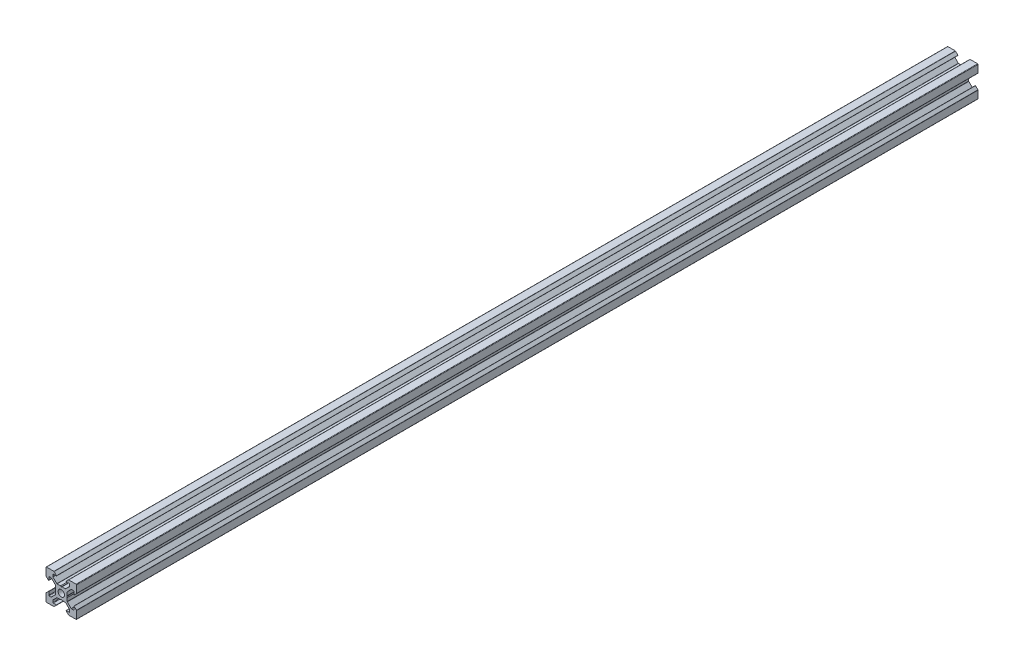
from build123d import *

# Parameters (mm, degrees)
BOSS_EXTRU_1_DEPTH = 590


with BuildPart() as part:
    # Esquisse1 → Boss.-Extru.1 (new body)
    with BuildSketch(Plane.XY):
        with BuildLine():
            Line((18.774857412, -2.895228684), (18.774857412, -4.894568513))
            ThreePointArc((18.774857412, -4.894568513), (18.686989447, -5.106700547), (18.474857412, -5.194568513))
            Line((18.474857412, -5.194568513), (17.259121481, -5.194568513))
            ThreePointArc((17.259121481, -5.194568513), (17.144316451, -5.171732372), (17.046989447, -5.106700547))
            Line((17.046989447, -5.106700547), (14.56338555, -2.62309665))
            ThreePointArc((14.56338555, -2.62309665), (14.498353724, -2.525769645), (14.475517584, -2.410964616))
            Line((14.475517584, -2.410964616), (14.475517584, -0.214843927))
            Line((14.475517584, -0.214843927), (14.175517584, 0.304771316))
            Line((14.175517584, 0.304771316), (14.475517584, 0.824386558))
            Line((14.475517584, 0.824386558), (14.475517584, 3.020507247))
            ThreePointArc((14.475517584, 3.020507247), (14.498353724, 3.135312277), (14.56338555, 3.232639281))
            Line((14.56338555, 3.232639281), (17.046989447, 5.716243178))
            ThreePointArc((17.046989447, 5.716243178), (17.144316451, 5.781275004), (17.259121481, 5.804111144))
            Line((17.259121481, 5.804111144), (18.474857412, 5.804111144))
            ThreePointArc((18.474857412, 5.804111144), (18.686989447, 5.716243178), (18.774857412, 5.504111144))
            Line((18.774857412, 5.504111144), (18.774857412, 3.504771316))
            ThreePointArc((18.774857412, 3.504771316), (18.836589069, 3.412383362), (18.94556809, 3.434060638))
            Line((18.94556809, 3.434060638), (20.486989447, 4.975481994))
            ThreePointArc((20.486989447, 4.975481994), (20.552021272, 5.072808998), (20.574857412, 5.187614028))
            Line((20.574857412, 5.187614028), (20.574857412, 10.004771316))
            ThreePointArc((20.574857412, 10.004771316), (20.486989447, 10.21690335), (20.274857412, 10.304771316))
            Line((20.274857412, 10.304771316), (15.457700125, 10.304771316))
            ThreePointArc((15.457700125, 10.304771316), (15.342895095, 10.281935175), (15.24556809, 10.21690335))
            Line((15.24556809, 10.21690335), (13.704146734, 8.675481994))
            ThreePointArc((13.704146734, 8.675481994), (13.682469459, 8.566502972), (13.774857412, 8.504771316))
            Line((13.774857412, 8.504771316), (15.77419724, 8.504771316))
            ThreePointArc((15.77419724, 8.504771316), (15.986329275, 8.41690335), (16.07419724, 8.204771316))
            Line((16.07419724, 8.204771316), (16.07419724, 6.989035384))
            ThreePointArc((16.07419724, 6.989035384), (16.0513611, 6.874230355), (15.986329275, 6.77690335))
            Line((15.986329275, 6.77690335), (13.502725378, 4.293299453))
            ThreePointArc((13.502725378, 4.293299453), (13.405398373, 4.228267628), (13.290593344, 4.205431487))
            Line((13.290593344, 4.205431487), (11.094472654, 4.205431487))
            Line((11.094472654, 4.205431487), (10.574857412, 3.905431487))
            Line((10.574857412, 3.905431487), (10.05524217, 4.205431487))
            Line((10.05524217, 4.205431487), (7.859121481, 4.205431487))
            ThreePointArc((7.859121481, 4.205431487), (7.744316451, 4.228267628), (7.646989447, 4.293299453))
            Line((7.646989447, 4.293299453), (5.16338555, 6.77690335))
            ThreePointArc((5.16338555, 6.77690335), (5.098353724, 6.874230355), (5.075517584, 6.989035384))
            Line((5.075517584, 6.989035384), (5.075517584, 8.204771316))
            ThreePointArc((5.075517584, 8.204771316), (5.16338555, 8.41690335), (5.375517584, 8.504771316))
            Line((5.375517584, 8.504771316), (7.374857412, 8.504771316))
            ThreePointArc((7.374857412, 8.504771316), (7.467245365, 8.566502972), (7.44556809, 8.675481994))
            Line((7.44556809, 8.675481994), (5.904146734, 10.21690335))
            ThreePointArc((5.904146734, 10.21690335), (5.806819729, 10.281935175), (5.6920147, 10.304771316))
            Line((5.6920147, 10.304771316), (0.874857412, 10.304771316))
            ThreePointArc((0.874857412, 10.304771316), (0.662725378, 10.21690335), (0.574857412, 10.004771316))
            Line((0.574857412, 10.004771316), (0.574857412, 5.187614028))
            ThreePointArc((0.574857412, 5.187614028), (0.597693552, 5.072808998), (0.662725378, 4.975481994))
            Line((0.662725378, 4.975481994), (2.204146734, 3.434060638))
            ThreePointArc((2.204146734, 3.434060638), (2.313125755, 3.412383362), (2.374857412, 3.504771316))
            Line((2.374857412, 3.504771316), (2.374857412, 5.504111144))
            ThreePointArc((2.374857412, 5.504111144), (2.462725378, 5.716243178), (2.674857412, 5.804111144))
            Line((2.674857412, 5.804111144), (3.890593344, 5.804111144))
            ThreePointArc((3.890593344, 5.804111144), (4.005398373, 5.781275004), (4.102725378, 5.716243178))
            Line((4.102725378, 5.716243178), (6.586329275, 3.232639281))
            ThreePointArc((6.586329275, 3.232639281), (6.6513611, 3.135312277), (6.67419724, 3.020507247))
            Line((6.67419724, 3.020507247), (6.67419724, 0.824386558))
            Line((6.67419724, 0.824386558), (6.97419724, 0.304771316))
            Line((6.97419724, 0.304771316), (6.67419724, -0.214843927))
            Line((6.67419724, -0.214843927), (6.67419724, -2.410964616))
            ThreePointArc((6.67419724, -2.410964616), (6.6513611, -2.525769645), (6.586329275, -2.62309665))
            Line((6.586329275, -2.62309665), (4.102725378, -5.106700547))
            ThreePointArc((4.102725378, -5.106700547), (4.005398373, -5.171732372), (3.890593344, -5.194568513))
            Line((3.890593344, -5.194568513), (2.674857412, -5.194568513))
            ThreePointArc((2.674857412, -5.194568513), (2.462725378, -5.106700547), (2.374857412, -4.894568513))
            Line((2.374857412, -4.894568513), (2.374857412, -2.895228684))
            ThreePointArc((2.374857412, -2.895228684), (2.313125755, -2.802840731), (2.204146734, -2.824518006))
            Line((2.204146734, -2.824518006), (0.662725378, -4.365939362))
            ThreePointArc((0.662725378, -4.365939362), (0.597693552, -4.463266367), (0.574857412, -4.578071397))
            Line((0.574857412, -4.578071397), (0.574857412, -9.395228684))
            ThreePointArc((0.574857412, -9.395228684), (0.662725378, -9.607360719), (0.874857412, -9.695228684))
            Line((0.874857412, -9.695228684), (5.6920147, -9.695228684))
            ThreePointArc((5.6920147, -9.695228684), (5.806819729, -9.672392544), (5.904146734, -9.607360719))
            Line((5.904146734, -9.607360719), (7.44556809, -8.065939362))
            ThreePointArc((7.44556809, -8.065939362), (7.467245365, -7.956960341), (7.374857412, -7.895228684))
            Line((7.374857412, -7.895228684), (5.375517584, -7.895228684))
            ThreePointArc((5.375517584, -7.895228684), (5.16338555, -7.807360719), (5.075517584, -7.595228684))
            Line((5.075517584, -7.595228684), (5.075517584, -6.379492753))
            ThreePointArc((5.075517584, -6.379492753), (5.098353724, -6.264687723), (5.16338555, -6.167360719))
            Line((5.16338555, -6.167360719), (7.646989447, -3.683756822))
            ThreePointArc((7.646989447, -3.683756822), (7.744316451, -3.618724996), (7.859121481, -3.595888856))
            Line((7.859121481, -3.595888856), (10.05524217, -3.595888856))
            Line((10.05524217, -3.595888856), (10.574857412, -3.295888856))
            Line((10.574857412, -3.295888856), (11.094472654, -3.595888856))
            Line((11.094472654, -3.595888856), (13.290593344, -3.595888856))
            ThreePointArc((13.290593344, -3.595888856), (13.405398373, -3.618724996), (13.502725378, -3.683756822))
            Line((13.502725378, -3.683756822), (15.986329275, -6.167360719))
            ThreePointArc((15.986329275, -6.167360719), (16.0513611, -6.264687723), (16.07419724, -6.379492753))
            Line((16.07419724, -6.379492753), (16.07419724, -7.595228684))
            ThreePointArc((16.07419724, -7.595228684), (15.986329275, -7.807360719), (15.77419724, -7.895228684))
            Line((15.77419724, -7.895228684), (13.774857412, -7.895228684))
            ThreePointArc((13.774857412, -7.895228684), (13.682469459, -7.956960341), (13.704146734, -8.065939362))
            Line((13.704146734, -8.065939362), (15.24556809, -9.607360719))
            ThreePointArc((15.24556809, -9.607360719), (15.342895095, -9.672392544), (15.457700125, -9.695228684))
            Line((15.457700125, -9.695228684), (20.274857412, -9.695228684))
            ThreePointArc((20.274857412, -9.695228684), (20.486989447, -9.607360719), (20.574857412, -9.395228684))
            Line((20.574857412, -9.395228684), (20.574857412, -4.578071397))
            ThreePointArc((20.574857412, -4.578071397), (20.552021272, -4.463266367), (20.486989447, -4.365939362))
            Line((20.486989447, -4.365939362), (18.94556809, -2.824518006))
            ThreePointArc((18.94556809, -2.824518006), (18.836589069, -2.802840731), (18.774857412, -2.895228684))
        make_face()
        with BuildLine():
            ThreePointArc((10.574857412, -1.795228684), (12.059781653, -1.180152925), (12.674857412, 0.304771316))
            ThreePointArc((12.674857412, 0.304771316), (12.059781653, 1.789695556), (10.574857412, 2.404771316))
            ThreePointArc((10.574857412, 2.404771316), (9.089933172, 1.789695556), (8.474857412, 0.304771316))
            ThreePointArc((8.474857412, 0.304771316), (9.089933172, -1.180152925), (10.574857412, -1.795228684))
        make_face(mode=Mode.SUBTRACT)
    extrude(amount=BOSS_EXTRU_1_DEPTH)


solid = part.part
